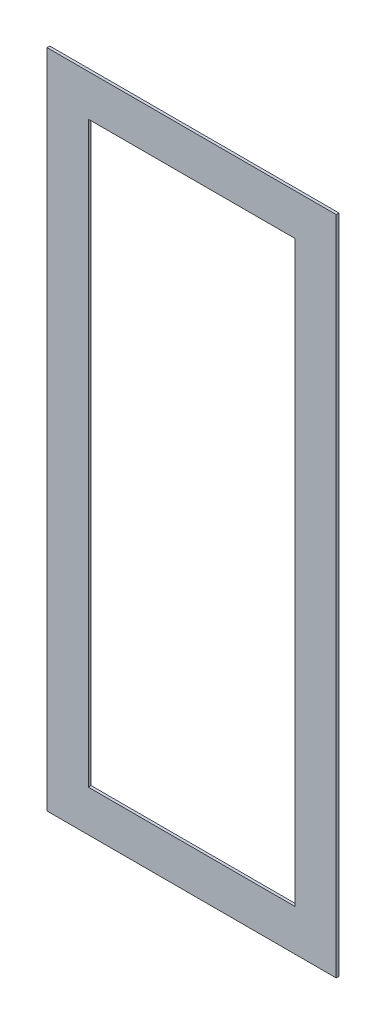
from build123d import *

# Parameters (mm, degrees)
SKETCH1_W           = 21
SKETCH1_H           = 48
SKETCH1_W_2         = 15
SKETCH1_H_2         = 42
BOSS_EXTRUDE1_DEPTH = 0.2


with BuildPart() as part:
    # Sketch1 → Boss-Extrude1 (new body)
    with BuildSketch(Plane.XY):
        Rectangle(SKETCH1_W, SKETCH1_H)
        Rectangle(SKETCH1_W_2, SKETCH1_H_2, mode=Mode.SUBTRACT)
    extrude(amount=BOSS_EXTRUDE1_DEPTH)


solid = part.part
